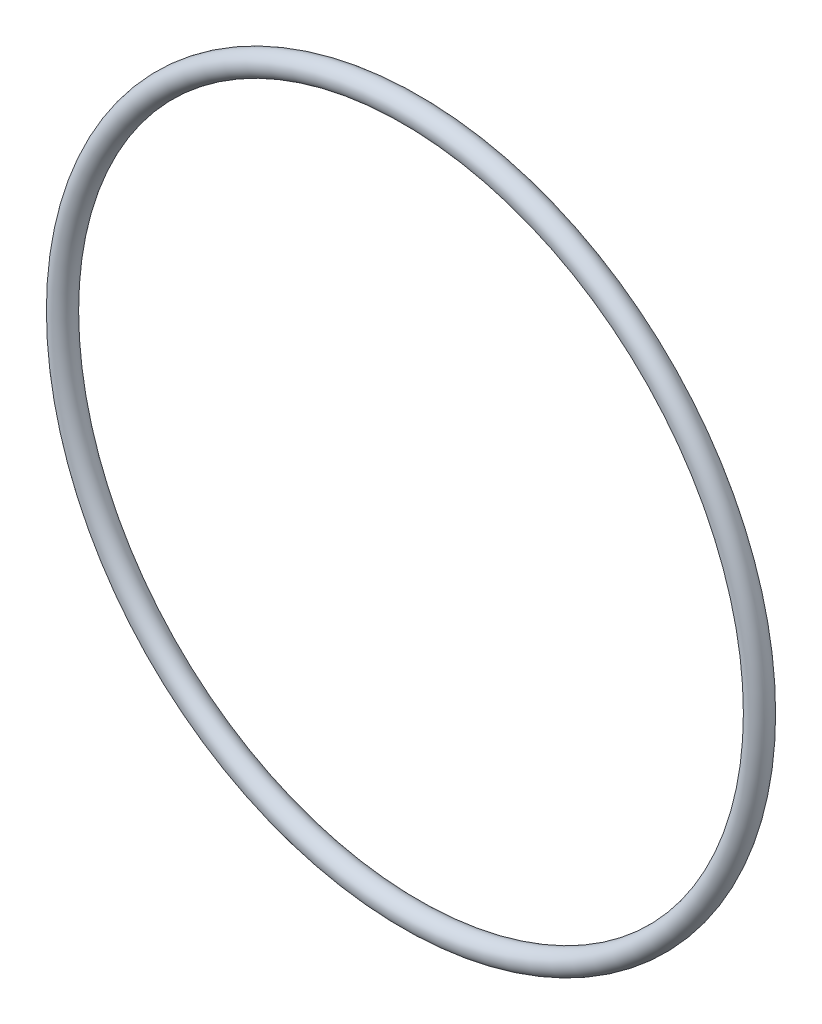
from build123d import *

# Parameters (mm, degrees)
SKETCH2_R = 1.7653


with BuildPart() as part:
    # Sketch2 → Revolve1 (revolve)
    with BuildSketch(Plane(origin=(0, 0, 0), x_dir=(1, 0, 0), z_dir=(0, 1, 0))):
        with Locations((-53.9496, 0)):
            Circle(SKETCH2_R)
    revolve(axis=Axis((0, 0, 1.7653), (0, 0, -1)))


solid = part.part
